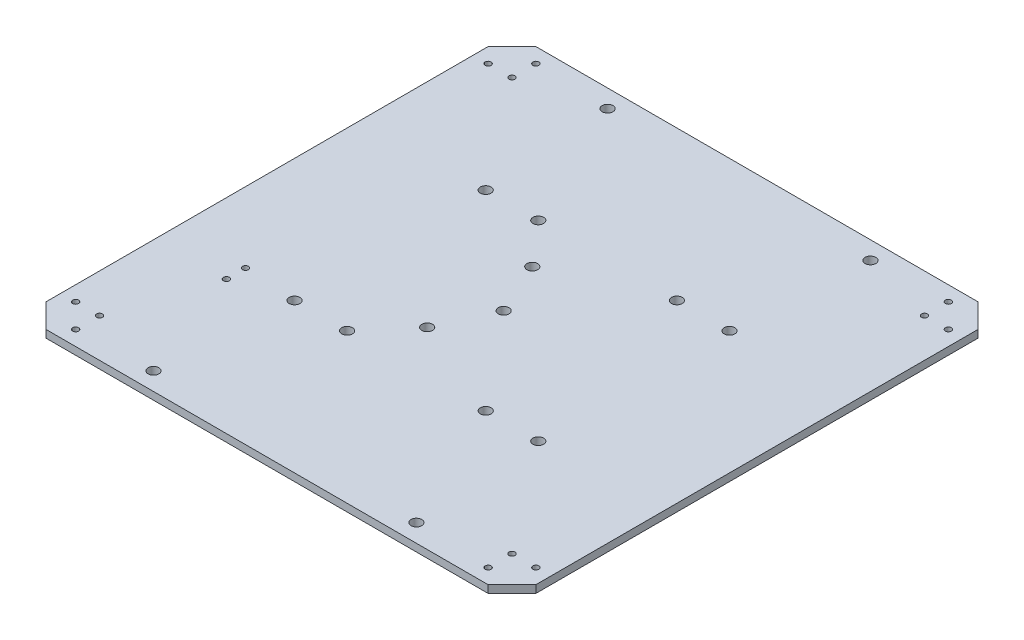
from build123d import *

# Parameters (mm, degrees)
BOSS_EXTRUDE1_DEPTH   = 3.175
SKETCH2_R             = 2.25
CUT_EXTRUDE1_DEPTH    = 4.175
M3X0_5_TAPPED_HOLE1_D = 2.5
SKETCH5_R             = 2.25
CUT_EXTRUDE2_DEPTH    = 4.175
SKETCH6_R             = 1.25
CUT_EXTRUDE3_DEPTH    = 10


with BuildPart() as part:
    # Sketch1 → Boss-Extrude1 (new body)
    with BuildSketch(Plane(origin=(0, 0, 0), x_dir=(1, 0, 0), z_dir=(0, 1, 0))):
        Polygon((-92.5, 102.5), (92.5, 102.5), (102.5, 92.5), (102.5, -92.5), (92.5, -102.5), (-92.5, -102.5), (-102.5, -92.5), (-102.5, 92.5), align=None)
    extrude(amount=BOSS_EXTRUDE1_DEPTH)

    # Sketch2 → Cut-Extrude1 (cut, through all)
    with BuildSketch(Plane(origin=(0, 3.175, 0), x_dir=(1, 0, 0), z_dir=(0, 1, 0))):
        with Locations(Location((-51, -40, 0), (0, 0, 270))):  # turned: the seam where the file's is
            Circle(SKETCH2_R)
        with Locations(Location((-29, -40, 0), (0, 0, 270))):  # turned: the seam where the file's is
            Circle(SKETCH2_R)
        with Locations(Location((-51, 40, 0), (0, 0, 270))):  # turned: the seam where the file's is
            Circle(SKETCH2_R)
        with Locations(Location((-29, 40, 0), (0, 0, 270))):  # turned: the seam where the file's is
            Circle(SKETCH2_R)
        with Locations(Location((29, 40, 0), (0, 0, 270))):  # turned: the seam where the file's is
            Circle(SKETCH2_R)
        with Locations(Location((51, 40, 0), (0, 0, 270))):  # turned: the seam where the file's is
            Circle(SKETCH2_R)
        with Locations(Location((29, -40, 0), (0, 0, 270))):  # turned: the seam where the file's is
            Circle(SKETCH2_R)
        with Locations(Location((51, -40, 0), (0, 0, 270))):  # turned: the seam where the file's is
            Circle(SKETCH2_R)
        with Locations(Location((-3.5, 0, 0), (0, 0, 270))):  # turned: the seam where the file's is
            Circle(SKETCH2_R)
        with Locations(Location((-13.5, 22, 0), (0, 0, 270))):  # turned: the seam where the file's is
            Circle(SKETCH2_R)
        with Locations(Location((-13.5, -22, 0), (0, 0, 270))):  # turned: the seam where the file's is
            Circle(SKETCH2_R)
    extrude(amount=-CUT_EXTRUDE1_DEPTH, mode=Mode.SUBTRACT)

    # M3x0.5 Tapped Hole1 (through all)
    with Locations(Plane(origin=(0, 3.175, 0), x_dir=(-1, 0, 0), z_dir=(0, 1, 0))):
        with Locations((96.3, -86.3), (86.3, -96.3), (-86.3, -96.3), (-96.3, -86.3), (-96.3, 86.3), (-86.3, 96.3), (86.3, 96.3), (96.3, 86.3), (-86.3, 86.3), (-86.3, -86.3), (86.3, -86.3), (86.3, 86.3)):
            Hole(M3X0_5_TAPPED_HOLE1_D / 2)

    # Sketch5 → Cut-Extrude2 (cut, through all)
    with BuildSketch(Plane(origin=(0, 3.175, 0), x_dir=(1, 0, 0), z_dir=(0, 1, 0))):
        with Locations(Location((-55, 95, 0), (0, 0, 270))):  # turned: the seam where the file's is
            Circle(SKETCH5_R)
        with Locations(Location((55, 95, 0), (0, 0, 270))):  # turned: the seam where the file's is
            Circle(SKETCH5_R)
        with Locations(Location((-55, -95, 0), (0, 0, 270))):  # turned: the seam where the file's is
            Circle(SKETCH5_R)
        with Locations(Location((55, -95, 0), (0, 0, 270))):  # turned: the seam where the file's is
            Circle(SKETCH5_R)
    extrude(amount=-CUT_EXTRUDE2_DEPTH, mode=Mode.SUBTRACT)

    # Sketch6 → Cut-Extrude3 (cut)
    with BuildSketch(Plane(origin=(0, 3.175, 0), x_dir=(1, 0, 0), z_dir=(0, 1, 0))):
        with Locations(Location((-73, -46.5, 0), (0, 0, 270))):  # turned: the seam where the file's is
            Circle(SKETCH6_R)
        with Locations(Location((-73, -38.5, 0), (0, 0, 270))):  # turned: the seam where the file's is
            Circle(SKETCH6_R)
    extrude(amount=-CUT_EXTRUDE3_DEPTH, mode=Mode.SUBTRACT)


solid = part.part
